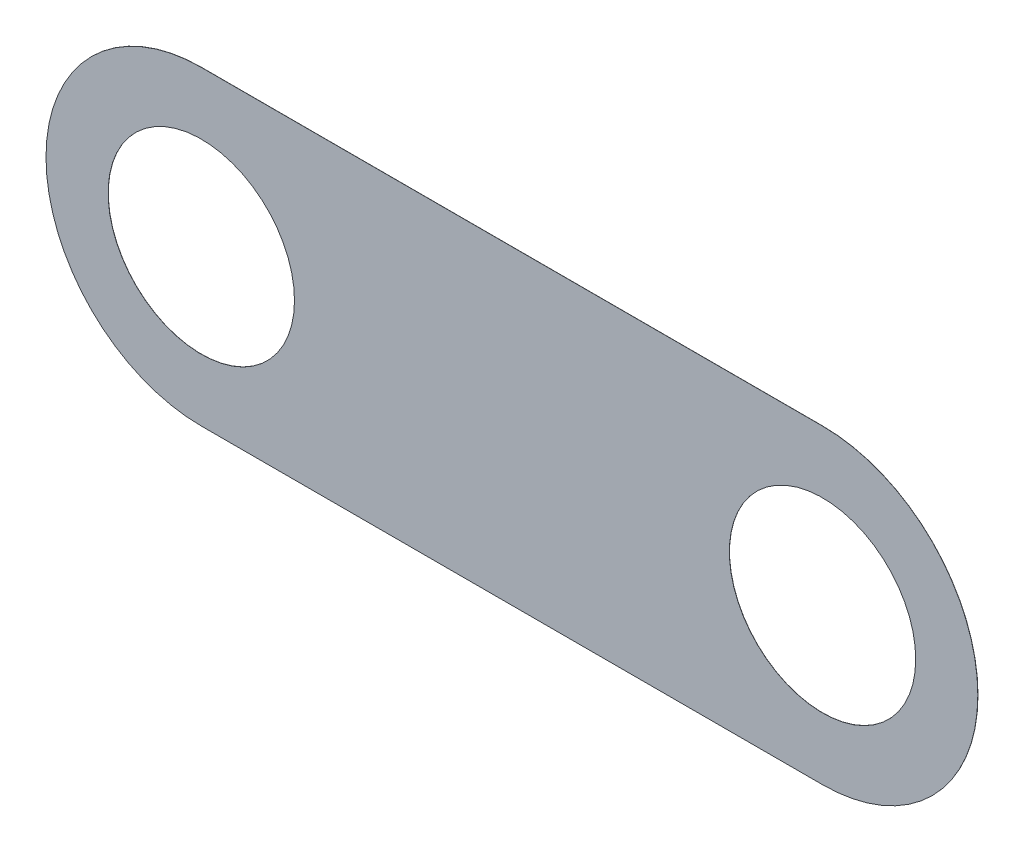
from build123d import *

# Parameters (mm, degrees)
SZKIC1_R                    = 6
DODANIE_WYCI_GNI_CIE1_DEPTH = 0.01


with BuildPart() as part:
    # Szkic1 → Dodanie-wyciągnięcie1 (new body)
    with BuildSketch(Plane.XY):
        with BuildLine():
            Line((0, 10), (40, 10))
            ThreePointArc((40, 10), (50, 0), (40, -10))
            Line((40, -10), (0, -10))
            ThreePointArc((0, -10), (-10, 0), (0, 10))
        make_face()
        Circle(SZKIC1_R, mode=Mode.SUBTRACT)
        with Locations((40, 0)):
            Circle(SZKIC1_R, mode=Mode.SUBTRACT)
    extrude(amount=DODANIE_WYCI_GNI_CIE1_DEPTH)


solid = part.part
